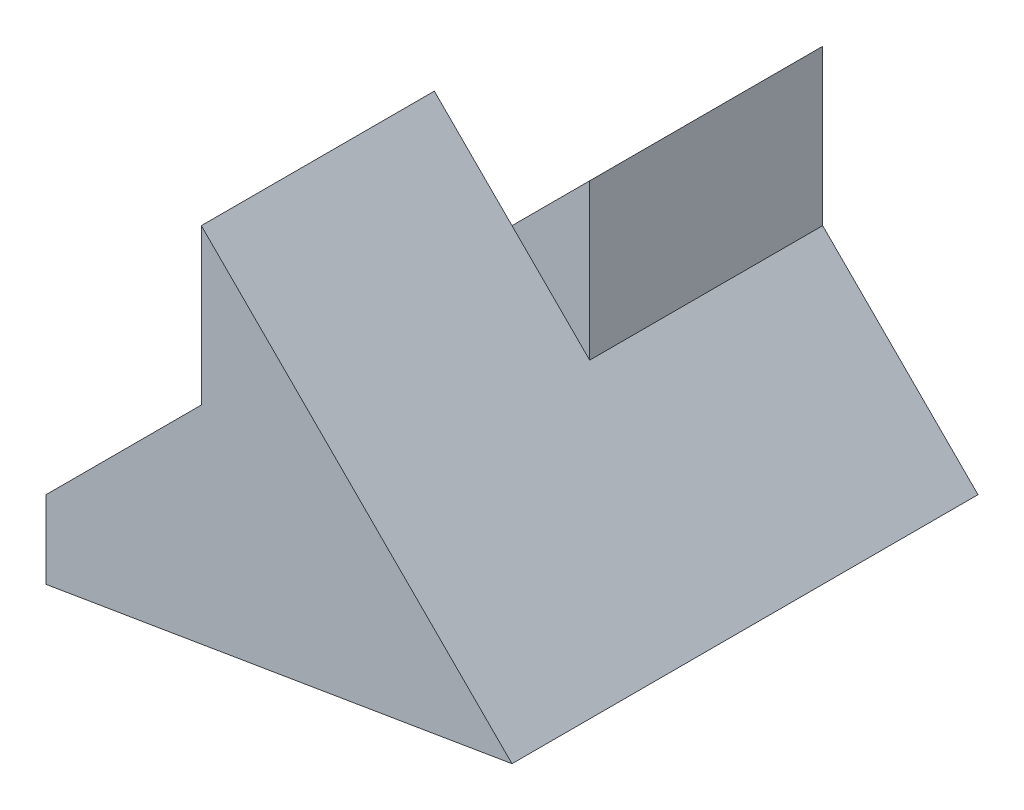
from build123d import *

# Parameters (mm, degrees)
BOSS_EXTRUDE1_DEPTH = 3
BOSS_EXTRUDE2_DEPTH = 3


with BuildPart() as part:
    # Sketch2 → Boss-Extrude1 (new body)
    with BuildSketch(Plane.XY):
        Polygon((0, 0), (6, 1), (2, 5), (2, 3), (0, 1), align=None)
    extrude(amount=BOSS_EXTRUDE1_DEPTH)

    # Sketch3 → Boss-Extrude2 (add)
    with BuildSketch(Plane(origin=(0, 0, 0), x_dir=(-1, 0, 0), z_dir=(0, 0, -1))):
        Polygon((0, 0), (0, 1), (-4, 5), (-4, 3), (-6, 1), align=None)
    extrude(amount=BOSS_EXTRUDE2_DEPTH)


solid = part.part
